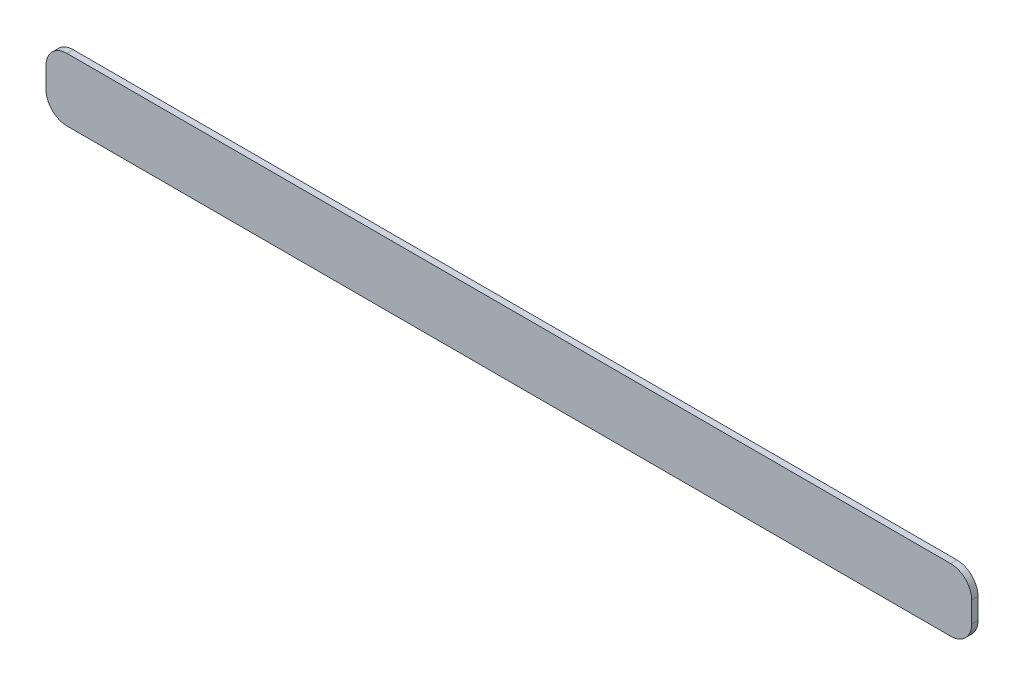
from build123d import *

# Parameters (mm, degrees)
BOSS_EXTRU_1_DEPTH = 3


with BuildPart() as part:
    # Esquisse1 → Boss.-Extru.1 (new body)
    with BuildSketch(Plane.XY):
        with BuildLine():
            Line((10, 0), (429.9, 0))
            ThreePointArc((429.9, 0), (436.971067812, 2.928932188), (439.9, 10))
            Line((439.9, 10), (439.9, 19.9))
            ThreePointArc((439.9, 19.9), (436.971067812, 26.971067812), (429.9, 29.9))
            Line((429.9, 29.9), (10, 29.9))
            ThreePointArc((10, 29.9), (2.928932188, 26.971067812), (0, 19.9))
            Line((0, 19.9), (0, 10))
            ThreePointArc((0, 10), (2.928932188, 2.928932188), (10, 0))
        make_face()
    extrude(amount=BOSS_EXTRU_1_DEPTH)


solid = part.part
